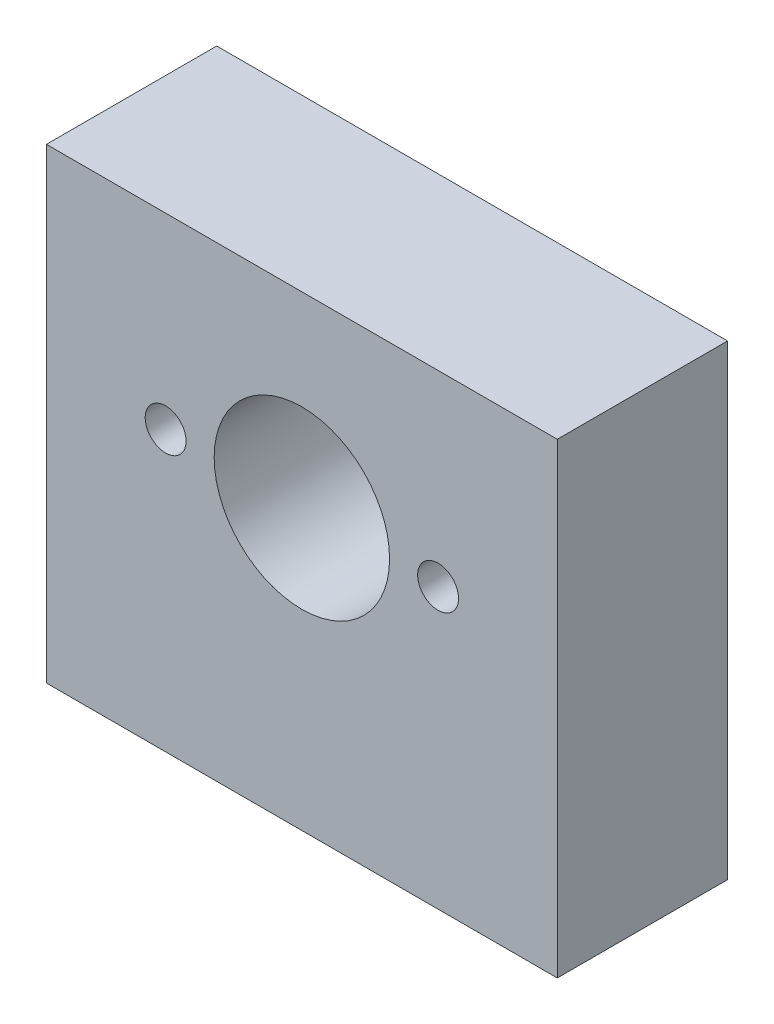
from build123d import *

# Parameters (mm, degrees)
SKETCH1_W           = 30
SKETCH1_H           = 27.4
SKETCH1_R           = 5.15
BOSS_EXTRUDE1_DEPTH = 10
SKETCH2_R           = 2
CUT_EXTRUDE1_DEPTH  = 10
SKETCH7_R           = 1.2
CUT_EXTRUDE2_DEPTH  = 11


with BuildPart() as part:
    # Sketch1 → Boss-Extrude1 (new body)
    with BuildSketch(Plane.XY):
        with Locations((0, -2.7)):
            Rectangle(SKETCH1_W, SKETCH1_H)
        Circle(SKETCH1_R, mode=Mode.SUBTRACT)
    extrude(amount=BOSS_EXTRUDE1_DEPTH)

    # Sketch2 → Cut-Extrude1 (cut)
    with BuildSketch(Plane.XZ.offset(16.4)):
        with Locations((-11, 5)):
            Circle(SKETCH2_R)
        with Locations((11, 5)):
            Circle(SKETCH2_R)
    extrude(amount=-CUT_EXTRUDE1_DEPTH, mode=Mode.SUBTRACT)

    # Sketch7 → Cut-Extrude2 (cut, through all)
    with BuildSketch(Plane.XY.offset(10)):
        with Locations((-8, 0)):
            Circle(SKETCH7_R)
        with Locations((8, 0)):
            Circle(SKETCH7_R)
    extrude(amount=-CUT_EXTRUDE2_DEPTH, mode=Mode.SUBTRACT)


solid = part.part
